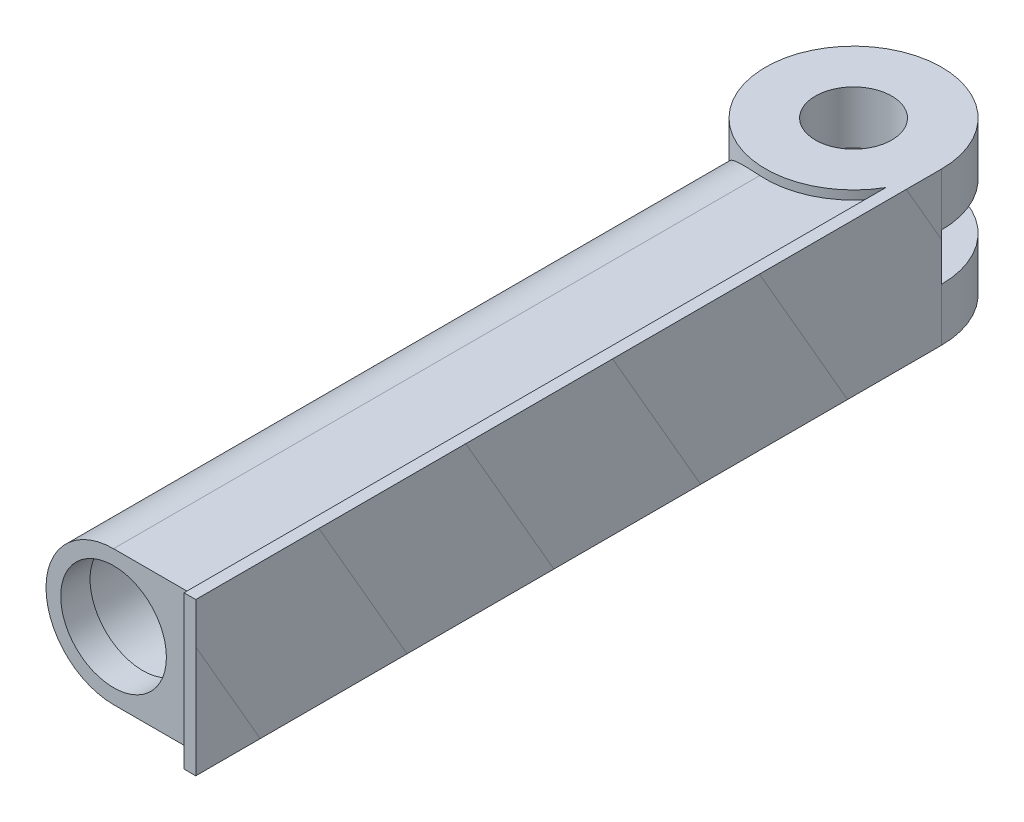
from build123d import *

# Parameters (mm, degrees)
SKETCH1_R           = 30
BOSS_EXTRUDE1_DEPTH = 26
BOSS_EXTRUDE2_DEPTH = 250
SKETCH4_R           = 13
CUT_EXTRUDE2_DEPTH  = 26
SKETCH1_2_R         = 30
CUT_EXTRUDE3_DEPTH  = 8
CUT_EXTRUDE4_START  = 8
SKETCH1_3_R         = 30
CUT_EXTRUDE4_DEPTH  = 8
SKETCH5_R           = 19
CUT_EXTRUDE5_DEPTH  = 210
SKETCH7_W           = 4
SKETCH7_H           = 4
BOSS_EXTRUDE4_DEPTH = 26
SKETCH9_R           = 19
SKETCH9_R_2         = 18
BOSS_EXTRUDE5_DEPTH = 10


with BuildPart() as part:
    # Sketch1 → Boss-Extrude1 (new, symmetric)
    with BuildSketch(Plane(origin=(0, 0, 0), x_dir=(1, 0, 0), z_dir=(0, 1, 0))):
        Circle(SKETCH1_R)
    extrude(amount=BOSS_EXTRUDE1_DEPTH, both=True)

    # Sketch3 → Boss-Extrude2 (add)
    with BuildSketch(Plane.XY):
        with BuildLine():
            Line((26, 26), (26, 23))
            Line((26, 23), (-2, 23))
            ThreePointArc((-2, 23), (-25, 0), (-2, -23))
            Line((-2, -23), (26, -23))
            Line((26, -23), (26, -26))
            Line((26, -26), (30, -26))
            Line((30, -26), (30, 26))
            Line((30, 26), (26, 26))
        make_face()
    extrude(amount=BOSS_EXTRUDE2_DEPTH)

    # Sketch4 → Cut-Extrude2 (cut, symmetric)
    with BuildSketch(Plane(origin=(0, 0, 0), x_dir=(1, 0, 0), z_dir=(0, 1, 0))):
        Circle(SKETCH4_R)
    extrude(amount=CUT_EXTRUDE2_DEPTH, both=True, mode=Mode.SUBTRACT)

    # Sketch1_2 → Cut-Extrude3 (cut)
    with BuildSketch(Plane(origin=(0, 0, 0), x_dir=(1, 0, 0), z_dir=(0, 1, 0))):
        Circle(SKETCH1_2_R)
    extrude(amount=-CUT_EXTRUDE3_DEPTH, mode=Mode.SUBTRACT)

    # Sketch1_3 → Cut-Extrude4 (cut)
    with BuildSketch(Plane(origin=(0, 0, 0), x_dir=(1, 0, 0), z_dir=(0, 1, 0)).offset(CUT_EXTRUDE4_START)):
        Circle(SKETCH1_3_R)
    extrude(amount=-CUT_EXTRUDE4_DEPTH, mode=Mode.SUBTRACT)

    # Sketch5 → Cut-Extrude5 (cut)
    with BuildSketch(Plane.XY.offset(250)):
        with Locations((-2, 0)):
            Circle(SKETCH5_R)
    extrude(amount=-CUT_EXTRUDE5_DEPTH, mode=Mode.SUBTRACT)

    # Sketch7 → Boss-Extrude4 (add, symmetric)
    with BuildSketch(Plane(origin=(0, 0, 0), x_dir=(1, 0, 0), z_dir=(0, 1, 0))):
        with Locations((28, -252)):
            Rectangle(SKETCH7_W, SKETCH7_H)
    extrude(amount=BOSS_EXTRUDE4_DEPTH, both=True)

    # Sketch9 → Boss-Extrude5 (add)
    with BuildSketch(Plane.XY.offset(250)):
        with Locations((-2, 0)):
            Circle(SKETCH9_R)
        with Locations((-2, 0)):
            Circle(SKETCH9_R_2, mode=Mode.SUBTRACT)
    extrude(amount=-BOSS_EXTRUDE5_DEPTH)


solid = part.part
